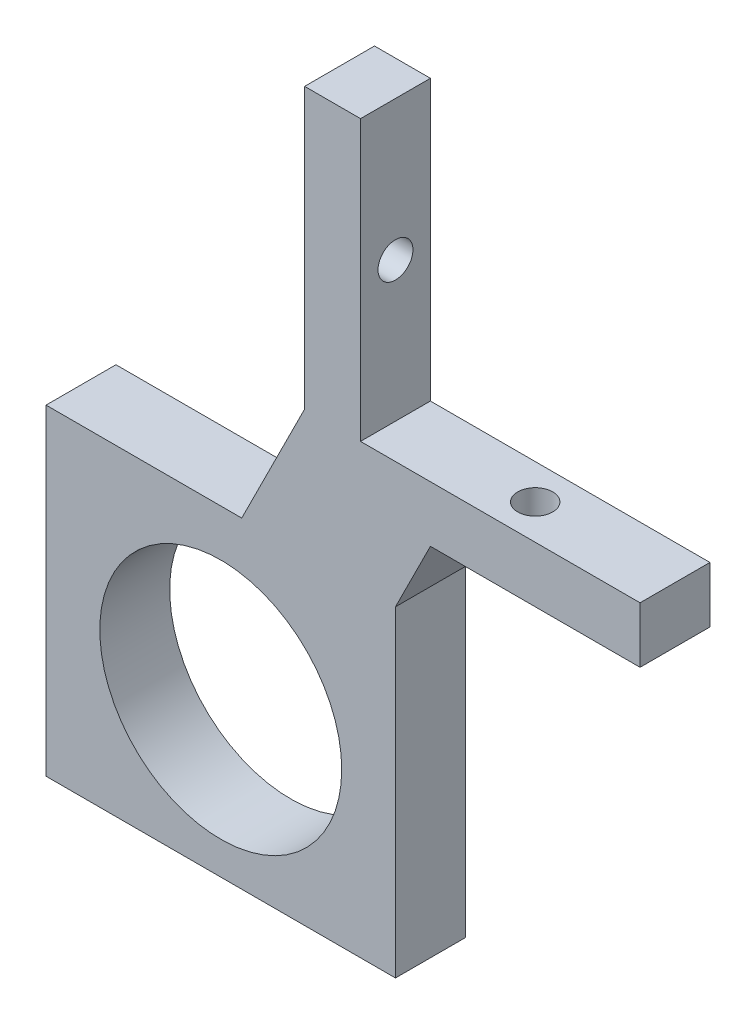
from build123d import *

# Parameters (mm, degrees)
SKETCH1_W           = 27.94
SKETCH1_H           = 27.94
SKETCH1_W_2         = 5.08
SKETCH1_H_2         = 66.04
BOSS_EXTRUDE1_DEPTH = 6.35
SKETCH2_R           = 1.5875
CUT_EXTRUDE1_DEPTH  = 12.7
SKETCH3_W           = 6.35
SKETCH3_H           = 5.08
BOSS_EXTRUDE2_DEPTH = 25.4
SKETCH4_R           = 1.5875
CUT_EXTRUDE2_DEPTH  = 25.4
SKETCH5_R           = 10.99185
CUT_EXTRUDE3_DEPTH  = 25.4
BOSS_EXTRUDE3_DEPTH = 6.35
SKETCH8_W           = 31.75
SKETCH8_H           = 29.21
SKETCH8_R           = 10.99185
BOSS_EXTRUDE4_DEPTH = 6.35
SKETCH9_W           = 4.445
SKETCH9_H           = 27.94
CUT_EXTRUDE4_DEPTH  = 6.35


with BuildPart() as part:
    # Sketch1 → Boss-Extrude1 (new body)
    with BuildSketch(Plane.XY):
        with Locations((-16.51, -19.05)):
            Rectangle(SKETCH1_W, SKETCH1_H)
        Rectangle(SKETCH1_W_2, SKETCH1_H_2)
    extrude(amount=BOSS_EXTRUDE1_DEPTH)

    # Sketch2 → Cut-Extrude1 (cut)
    with BuildSketch(Plane.ZY.offset(2.54)):
        with Locations((3.175, 20.32)):
            Circle(SKETCH2_R)
    extrude(amount=-CUT_EXTRUDE1_DEPTH, mode=Mode.SUBTRACT)

    # Sketch3 → Boss-Extrude2 (add)
    with BuildSketch(Plane(origin=(2.54, 0, 0), x_dir=(0, 0, -1), z_dir=(1, 0, 0))):
        with Locations((-3.175, 5.08)):
            Rectangle(SKETCH3_W, SKETCH3_H)
    extrude(amount=BOSS_EXTRUDE2_DEPTH)

    # Sketch4 → Cut-Extrude2 (cut)
    with BuildSketch(Plane.XZ.offset(-2.54)):
        with Locations((15.24, 3.175)):
            Circle(SKETCH4_R)
    extrude(amount=-CUT_EXTRUDE2_DEPTH, mode=Mode.SUBTRACT)

    # Sketch5 → Cut-Extrude3 (cut)
    with BuildSketch(Plane.XY.offset(6.35)):
        with Locations((-10.16, -19.05)):
            Circle(SKETCH5_R)
    extrude(amount=-CUT_EXTRUDE3_DEPTH, mode=Mode.SUBTRACT)

    # Sketch6 → Boss-Extrude3 (add)
    with BuildSketch(Plane.XY.offset(6.35)):
        Polygon((-2.54, 7.62), (-8.89, -5.08), (-2.54, -5.08), align=None)
        Polygon((2.54, 2.54), (2.54, -10.16), (8.89, 2.54), align=None)
    extrude(amount=-BOSS_EXTRUDE3_DEPTH)

    # Sketch8 → Boss-Extrude4 (add)
    with BuildSketch(Plane.XY.offset(6.35)):
        with Locations((-10.16, -18.415)):
            Rectangle(SKETCH8_W, SKETCH8_H)
        with Locations((-10.16, -19.05)):
            Circle(SKETCH8_R, mode=Mode.SUBTRACT)
    extrude(amount=-BOSS_EXTRUDE4_DEPTH)

    # Sketch9 → Cut-Extrude4 (cut)
    with BuildSketch(Plane.XY.offset(6.35)):
        with Locations((-28.2575, -19.05)):
            Rectangle(SKETCH9_W, SKETCH9_H)
    extrude(amount=-CUT_EXTRUDE4_DEPTH, mode=Mode.SUBTRACT)


solid = part.part
